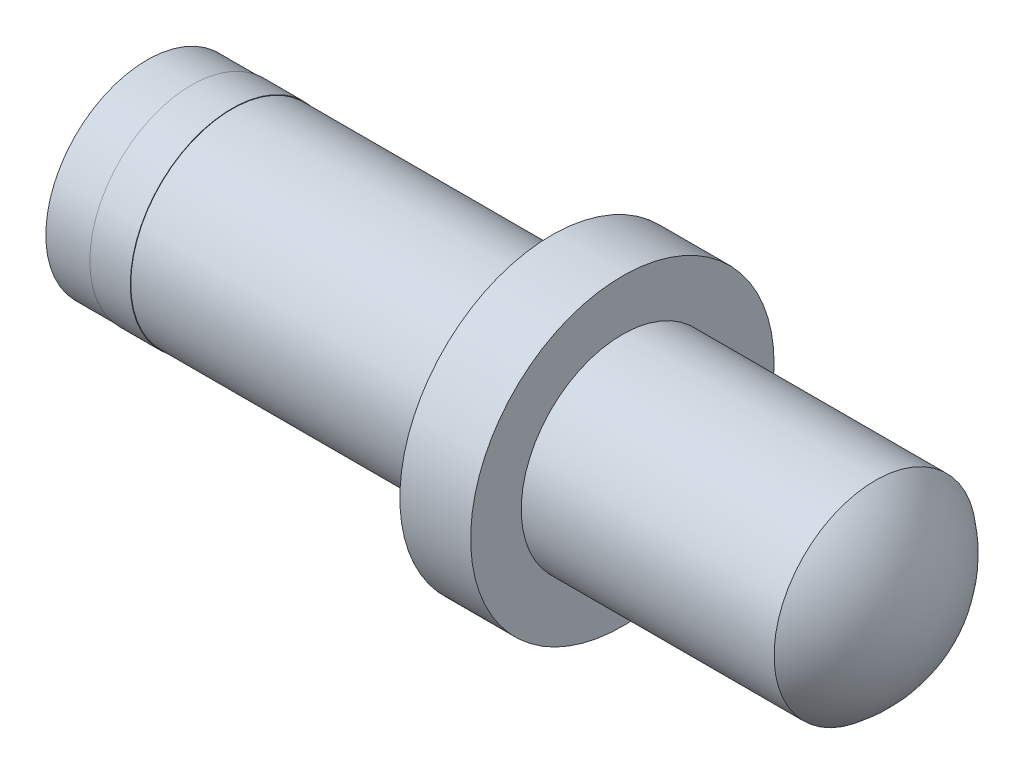
from build123d import *

# Parameters (mm, degrees)
D_ME1_FACE_RADIUS = 2
D_ME1_HEIGHT      = 1
ESQUISSE4_R       = 2.01
EXTRUSION3_DEPTH  = 0.8


with BuildPart() as part:
    # Esquisse1 → R_volution1 (revolve)
    with BuildSketch(Plane.XY, mode=Mode.PRIVATE) as r_volution1_sk:
        Polygon((0, 0), (0, 2), (8, 2), (8, 3), (9.4, 3), (9.4, 2), (14.4, 2), (14.4, 0), align=None)
    revolve(r_volution1_sk.sketch.rotate(Axis((14.4, 0, 0), (-1, 0, 0)), 90), axis=Axis((14.4, 0, 0), (-1, 0, 0)))  # turned: the seam where the file's is

    # D_me1: a dome of height H over a round flat face of radius A is a cap of a sphere of radius (A * A + H * H) / (2 * H)
    d_me1_r = (D_ME1_FACE_RADIUS * D_ME1_FACE_RADIUS + D_ME1_HEIGHT * D_ME1_HEIGHT) / (2 * D_ME1_HEIGHT)
    d_me1_base = Plane((14.4, 0, 0), z_dir=(1, 0, 0))
    with Locations(d_me1_base.offset(D_ME1_HEIGHT - d_me1_r)):
        d_me1_ball = Sphere(d_me1_r, mode=Mode.PRIVATE)
    add(split(d_me1_ball, bisect_by=d_me1_base, keep=Keep.TOP, mode=Mode.PRIVATE))

    # Esquisse4 → Extrusion3 (add)
    with BuildSketch(Plane.ZY.offset(-1.68)):
        Circle(ESQUISSE4_R)
    extrude(amount=EXTRUSION3_DEPTH)


solid = part.part
